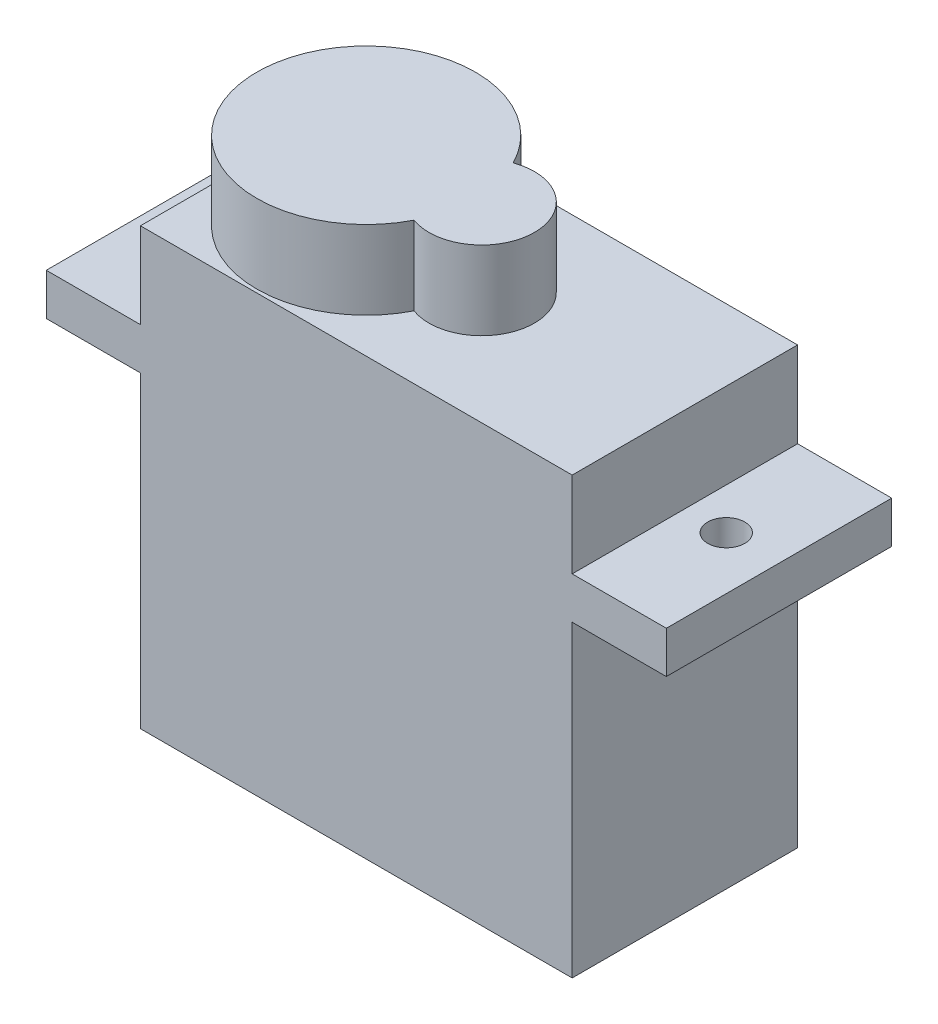
from build123d import *

# Parameters (mm, degrees)
SKETCH2_W                = 32.6
SKETCH2_H                = 11.85
BOSS_EXTRUDE2_DEPTH      = 2.2
SKETCH3_W                = 22.7
SKETCH3_H                = 11.85
BOSS_EXTRUDE3_DEPTH      = 4.5
BOSS_EXTRUDE3_DEPTH_BACK = 18.4
SKETCH4_R                = 0.975
CUT_EXTRUDE1_DEPTH       = 4.5
SKETCH5_R                = 5.75
SKETCH5_R_2              = 2.775
BOSS_EXTRUDE4_DEPTH      = 4.13


with BuildPart() as part:
    # Sketch2 → Boss-Extrude2 (new body)
    with BuildSketch(Plane(origin=(0, 0, 0), x_dir=(1, 0, 0), z_dir=(0, 1, 0))):
        Rectangle(SKETCH2_W, SKETCH2_H)
    extrude(amount=BOSS_EXTRUDE2_DEPTH)

    # Sketch3 → Boss-Extrude3 (add, two sides)
    with BuildSketch(Plane(origin=(0, 2.2, 0), x_dir=(1, 0, 0), z_dir=(0, 1, 0))) as boss_extrude3_sk:
        Rectangle(SKETCH3_W, SKETCH3_H)
    extrude(amount=BOSS_EXTRUDE3_DEPTH)
    extrude(boss_extrude3_sk.sketch, amount=-BOSS_EXTRUDE3_DEPTH_BACK)

    # Sketch4 → Cut-Extrude1 (cut)
    with BuildSketch(Plane(origin=(0, 2.2, 0), x_dir=(1, 0, 0), z_dir=(0, 1, 0))):
        with Locations((13.525, 0)):
            Circle(SKETCH4_R)
    cut_extrude1 = extrude(amount=-CUT_EXTRUDE1_DEPTH, mode=Mode.SUBTRACT)

    # Mirror1: Cut-Extrude1 across plane
    add(cut_extrude1.mirror(Plane(origin=(0, 0, 0), x_dir=(0, 0, 1), z_dir=(1, 0, 0))), mode=Mode.SUBTRACT)

    # Sketch5 → Boss-Extrude4 (add)
    with BuildSketch(Plane(origin=(0, 6.7, 0), x_dir=(1, 0, 0), z_dir=(0, 1, 0))):
        with Locations((-5.40813132, 0)):
            Circle(SKETCH5_R)
        with Locations((0.66686868, 0)):
            Circle(SKETCH5_R_2)
    extrude(amount=BOSS_EXTRUDE4_DEPTH)


solid = part.part
